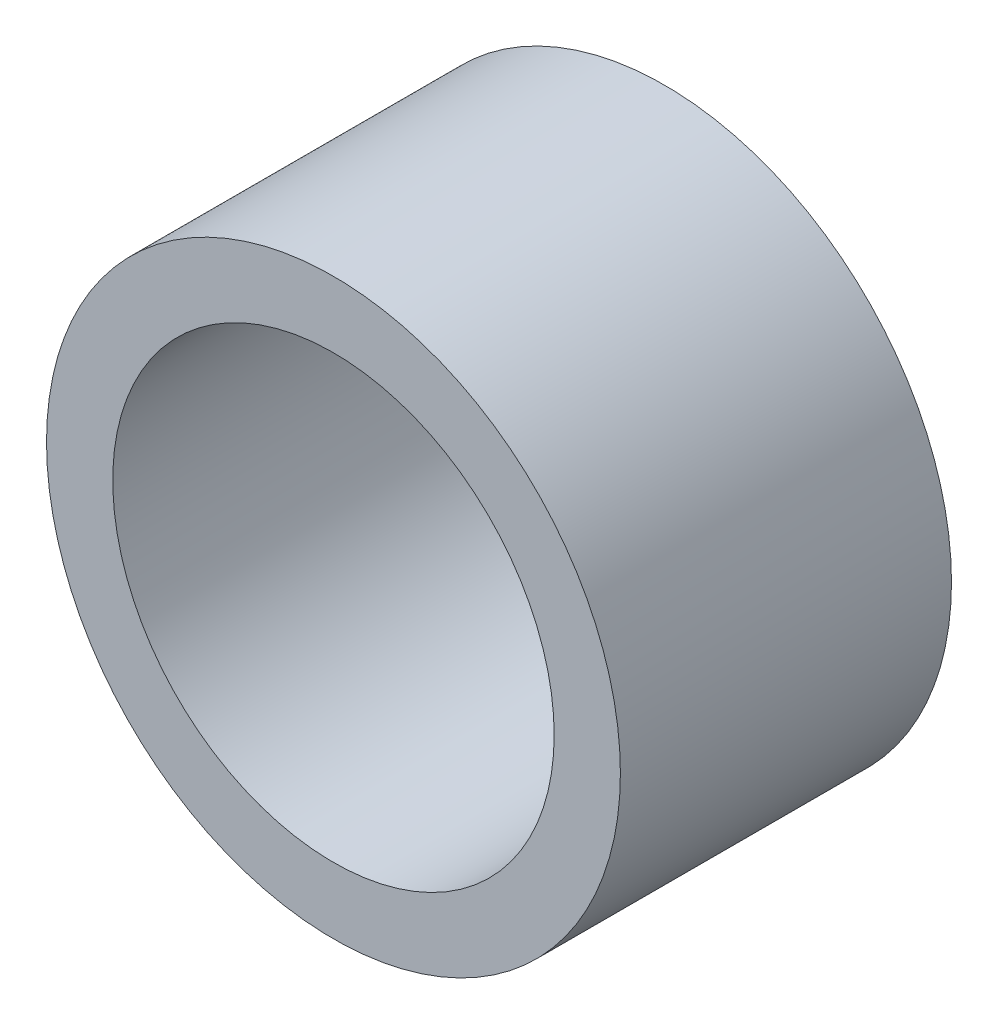
from build123d import *

# Parameters (mm, degrees)
SKETCH2_R           = 13
SKETCH2_R_2         = 10
BOSS_EXTRUDE1_DEPTH = 15


with BuildPart() as part:
    # Sketch2 → Boss-Extrude1 (new body)
    with BuildSketch(Plane.XY):
        Circle(SKETCH2_R)
        Circle(SKETCH2_R_2, mode=Mode.SUBTRACT)
    extrude(amount=BOSS_EXTRUDE1_DEPTH)


solid = part.part
